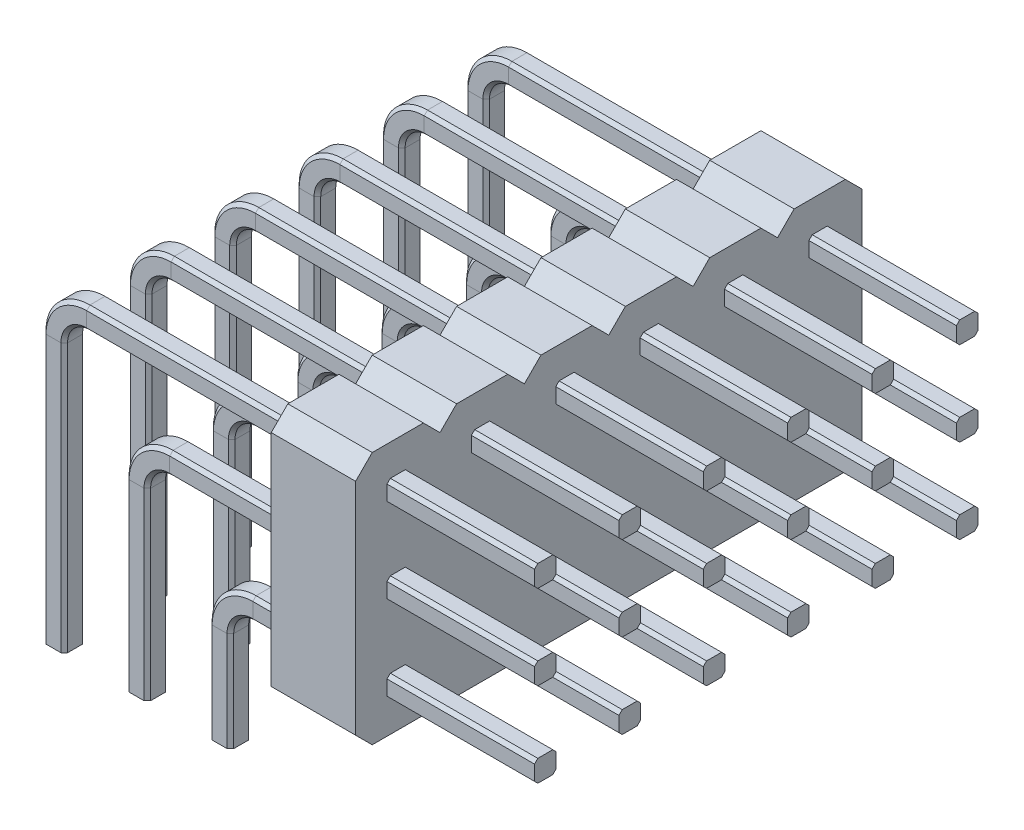
from build123d import *

# Parameters (mm, degrees)
BOSS_EXTRUDE1_DEPTH = 2.54
LPATTERN1_COUNT     = 6
LPATTERN1_PITCH     = 2.54


with BuildPart() as part:
    # Sweep1: sweep along a path in Sketch2
    with BuildLine(Plane.XY) as sweep1_path:
        Line((5, 0), (5, 3))
        ThreePointArc((5, 3), (5.292893219, 3.707106781), (6, 4))
        Line((6, 4), (14.48, 4))
    # Sketch1 → Sweep1 (sweep)
    with BuildSketch(Plane(origin=(0, 0, 0), x_dir=(1, 0, 0), z_dir=(0, 1, 0))):
        Polygon((4.775, -0.325), (5.225, -0.325), (5.325, -0.225), (5.325, 0.225), (5.225, 0.325), (4.775, 0.325), (4.675, 0.225), (4.675, -0.225), align=None)
    sweep(path=sweep1_path.line)



with BuildPart() as body_2:
    # Sweep2: sweep along a path in Sketch2_3
    with BuildLine(Plane.XY) as sweep2_path:
        Line((2.5, 0), (2.5, 5.54))
        ThreePointArc((2.5, 5.54), (2.792893219, 6.247106781), (3.5, 6.54))
        Line((3.5, 6.54), (14.48, 6.54))
    # Sketch1_3 → Sweep2 (sweep)
    with BuildSketch(Plane(origin=(0, 0, 0), x_dir=(1, 0, 0), z_dir=(0, 1, 0))):
        Polygon((2.275, -0.325), (2.725, -0.325), (2.825, -0.225), (2.825, 0.225), (2.725, 0.325), (2.275, 0.325), (2.175, 0.225), (2.175, -0.225), align=None)
    sweep(path=sweep2_path.line)


with BuildPart() as body_3:
    # Sweep3: sweep along a path in Sketch2_4
    with BuildLine(Plane.XY) as sweep3_path:
        Line((0, 0), (0, 8.08))
        ThreePointArc((0, 8.08), (0.292893219, 8.787106781), (1, 9.08))
        Line((1, 9.08), (14.48, 9.08))
    # Sketch1_4 → Sweep3 (sweep)
    with BuildSketch(Plane(origin=(0, 0, 0), x_dir=(1, 0, 0), z_dir=(0, 1, 0))):
        Polygon((-0.325, 0.225), (-0.225, 0.325), (0.225, 0.325), (0.325, 0.225), (0.325, -0.225), (0.225, -0.325), (-0.225, -0.325), (-0.325, -0.225), align=None)
    sweep(path=sweep3_path.line)


with BuildPart() as part_1:
    add(part.part)

    add(body_2.part)  # Boss-Extrude1 merges body 2

    add(body_3.part)  # Boss-Extrude1 merges body 3
    # Sketch4 → Boss-Extrude1 (add)
    with BuildSketch(Plane(origin=(7.5, 0, 0), x_dir=(0, 0, -1), z_dir=(1, 0, 0))):
        Polygon((-1.27, 9.85), (-0.77, 10.35), (0.77, 10.35), (1.27, 9.85), (1.27, 3.23), (0.77, 2.73), (-0.77, 2.73), (-1.27, 3.23), align=None)
    extrude(amount=BOSS_EXTRUDE1_DEPTH)


with BuildPart() as lpattern1_1:
    # LPattern1: pattern copy
    add(part_1.part.moved(Location(Vector(0, 0, 1) * (1 * LPATTERN1_PITCH))))


with BuildPart() as lpattern1_2:
    # LPattern1: pattern copy
    add(part_1.part.moved(Location(Vector(0, 0, 1) * (2 * LPATTERN1_PITCH))))


with BuildPart() as lpattern1_3:
    # LPattern1: pattern copy
    add(part_1.part.moved(Location(Vector(0, 0, 1) * (3 * LPATTERN1_PITCH))))


with BuildPart() as lpattern1_4:
    # LPattern1: pattern copy
    add(part_1.part.moved(Location(Vector(0, 0, 1) * (4 * LPATTERN1_PITCH))))


with BuildPart() as lpattern1_5:
    # LPattern1: pattern copy
    add(part_1.part.moved(Location(Vector(0, 0, 1) * (5 * LPATTERN1_PITCH))))


with BuildPart() as part_2:
    add(part_1.part)

    # Combine1: union LPattern1_1, LPattern1_2, LPattern1_3, LPattern1_4, LPattern1_5
    add(lpattern1_1.part)
    add(lpattern1_2.part)
    add(lpattern1_3.part)
    add(lpattern1_4.part)
    add(lpattern1_5.part)


solid = part_2.part
